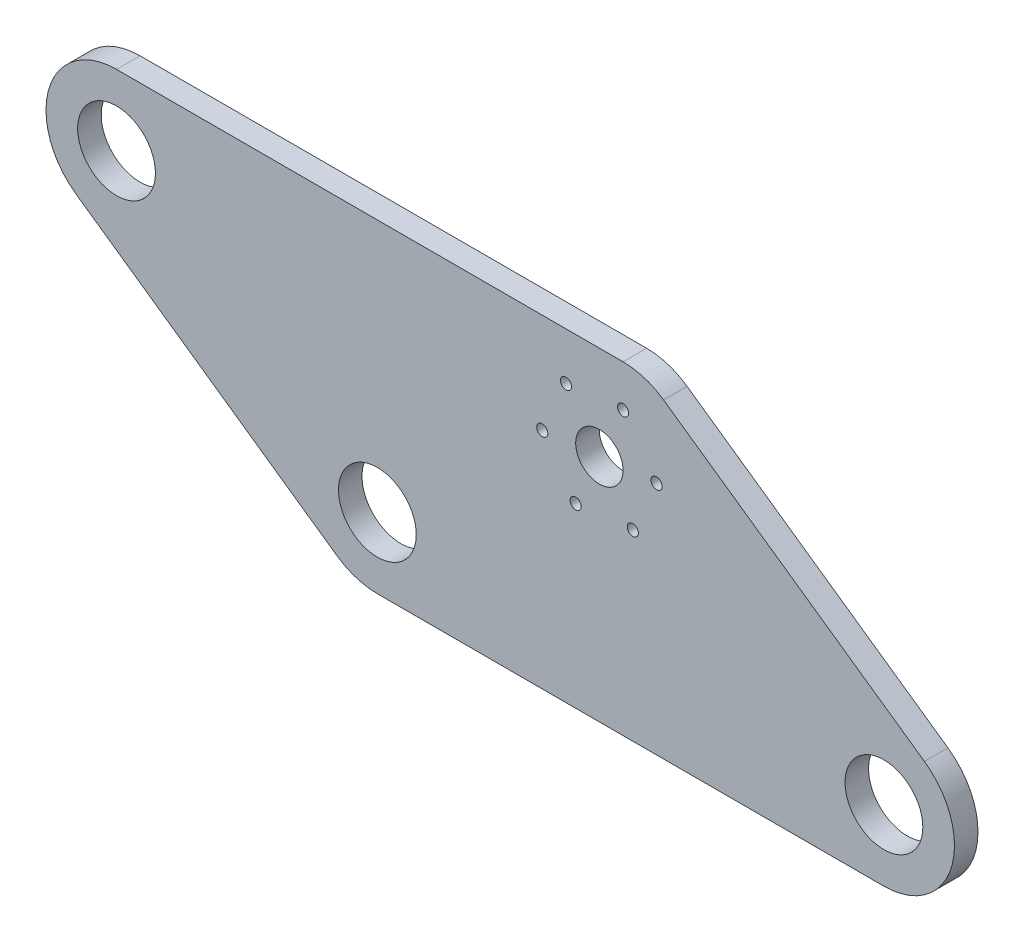
from build123d import *

# Parameters (mm, degrees)
BOSS_EXTRUDE1_DEPTH = 6.35
FILLET1_R           = 19.05
SKETCH4_R           = 10.5
SKETCH4_R_2         = 6.4
SKETCH4_R_3         = 1.5
CUT_EXTRUDE1_DEPTH  = 7.35


with BuildPart() as part:
    # Sketch3 → Boss-Extrude1 (new body)
    with BuildSketch(Plane.XY):
        Polygon((-152.4, 25.4), (50.8, 25.4), (175.63877155, -62.0130489), (-27.56122845, -62.0130489), align=None)
    extrude(amount=BOSS_EXTRUDE1_DEPTH)

    # Fillet1
    fillet1_edges = [part.edges().sort_by_distance(p)[0] for p in [
        (-152.4, 25.4, 3.175),
        (50.8, 25.4, 3.175),
        (175.63877155, -62.0130489, 3.175),
        (-27.56122845, -62.0130489, 3.175),
    ]]
    fillet(fillet1_edges, radius=FILLET1_R)

    # Sketch4 → Cut-Extrude1 (cut, through all)
    with BuildSketch(Plane.XY.offset(6.35)):
        with Locations((-91.981119015, 6.35)):
            Circle(SKETCH4_R)
        with Locations((38.393558072, 0)):
            Circle(SKETCH4_R_2)
        with Locations((-21.554786522, -42.9630489)):
            Circle(SKETCH4_R)
        with Locations((115.219890565, -42.9630489)):
            Circle(SKETCH4_R)
        with Locations((44.793558072, 14.117011015)):
            Circle(SKETCH4_R_3)
        with Locations((53.819248236, 1.515942923)):
            Circle(SKETCH4_R_3)
        with Locations((47.419248236, -12.601068092)):
            Circle(SKETCH4_R_3)
        with Locations((31.993558072, -14.117011015)):
            Circle(SKETCH4_R_3)
        with Locations((22.967867907, -1.515942923)):
            Circle(SKETCH4_R_3)
        with Locations((29.367867907, 12.601068092)):
            Circle(SKETCH4_R_3)
    extrude(amount=-CUT_EXTRUDE1_DEPTH, mode=Mode.SUBTRACT)


solid = part.part
